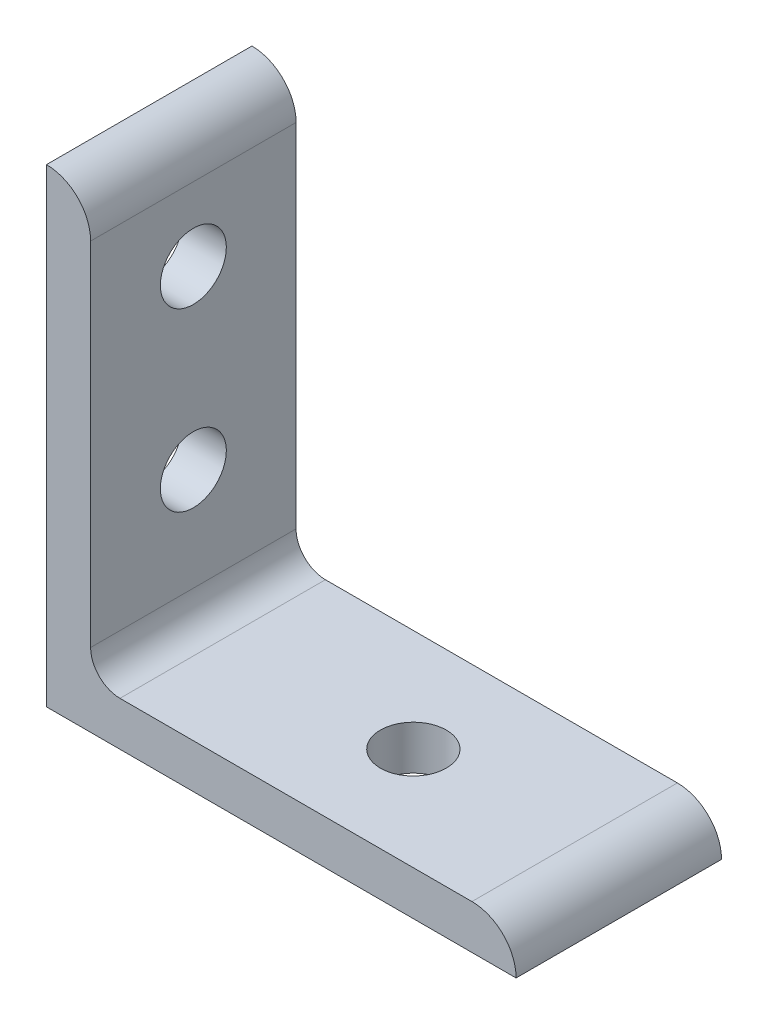
from build123d import *

# Parameters (mm, degrees)
BOSS_EXTRUDE1_DEPTH = 11.1125
SKETCH2_R           = 3.5687
CUT_EXTRUDE1_DEPTH  = 51.8
SKETCH3_R           = 3.5687
CUT_EXTRUDE2_DEPTH  = 51.8


with BuildPart() as part:
    # Sketch1 → Boss-Extrude1 (new body, symmetric)
    with BuildSketch(Plane.XY):
        with BuildLine():
            Line((0, 0), (0, 50.8))
            ThreePointArc((0, 50.8), (3.376576302, 49.401376302), (4.7752, 46.0248))
            Line((4.7752, 46.0248), (4.7752, 7.9502))
            ThreePointArc((4.7752, 7.9502), (5.70513597, 5.70513597), (7.9502, 4.7752))
            Line((7.9502, 4.7752), (46.0248, 4.7752))
            ThreePointArc((46.0248, 4.7752), (49.401376302, 3.376576302), (50.8, 0))
            Line((50.8, 0), (0, 0))
        make_face()
    extrude(amount=BOSS_EXTRUDE1_DEPTH, both=True)

    # Sketch2 → Cut-Extrude1 (cut, through all)
    with BuildSketch(Plane(origin=(0, 0, 0), x_dir=(1, 0, 0), z_dir=(0, 1, 0))):
        with Locations((28.575, 0)):
            Circle(SKETCH2_R)
    extrude(amount=CUT_EXTRUDE1_DEPTH, mode=Mode.SUBTRACT)

    # Sketch3 → Cut-Extrude2 (cut, through all)
    with BuildSketch(Plane(origin=(0, 0, 0), x_dir=(0, 0, -1), z_dir=(1, 0, 0))):
        with Locations((0, 19.05)):
            Circle(SKETCH3_R)
        with Locations((0, 38.1)):
            Circle(SKETCH3_R)
    extrude(amount=CUT_EXTRUDE2_DEPTH, mode=Mode.SUBTRACT)


solid = part.part
